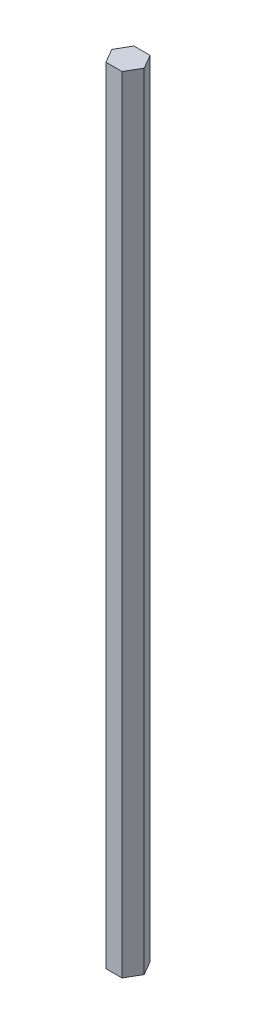
from build123d import *

# Parameters (mm, degrees)
BOSS_EXTRUDE1_DEPTH = 355.6


with BuildPart() as part:
    # Sketch1 → Boss-Extrude1 (new body)
    with BuildSketch(Plane(origin=(0, 0, 0), x_dir=(1, 0, 0), z_dir=(0, 1, 0))):
        Polygon((3.666174209, 6.35), (-3.666174209, 6.35), (-7.332348419, 0), (-3.666174209, -6.35), (3.666174209, -6.35), (7.332348419, 0), align=None)
    extrude(amount=BOSS_EXTRUDE1_DEPTH)


solid = part.part
